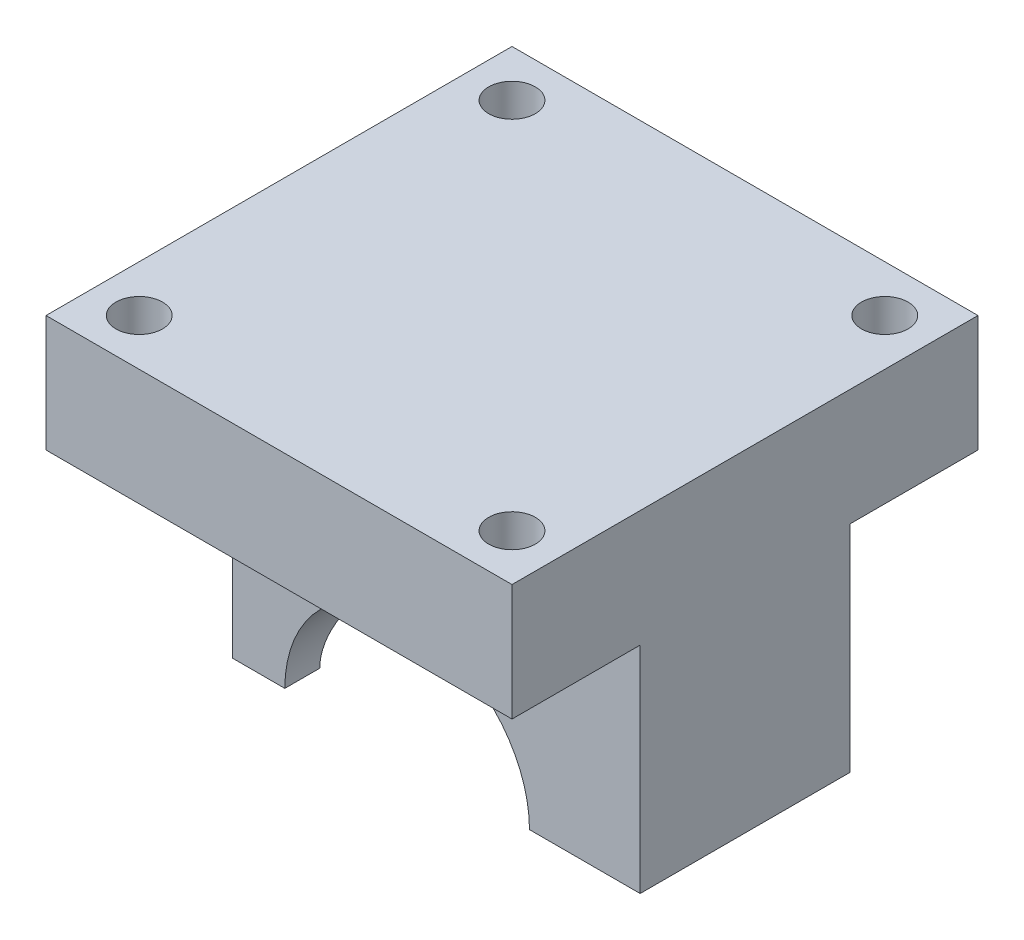
from build123d import *

# Parameters (mm, degrees)
SKETCH1_W           = 40
SKETCH1_H           = 18
BOSS_EXTRUDE1_DEPTH = 18.47
CUT_EXTRUDE1_REACH  = 20
SKETCH2_R           = 10.5
CUT_EXTRUDE3_REACH  = 42
SKETCH4_R           = 6
CUT_EXTRUDE4_REACH  = 20.47
SKETCH5_W           = 5
SKETCH5_H           = 18
SKETCH6_W           = 40
SKETCH6_H           = 40
BOSS_EXTRUDE2_DEPTH = 10
CUT_EXTRUDE5_REACH  = 12
SKETCH7_R           = 2


with BuildPart() as part:
    # Sketch1 → Boss-Extrude1 (new body)
    with BuildSketch(Plane(origin=(0, 0, 0), x_dir=(1, 0, 0), z_dir=(0, 1, 0))):
        Rectangle(SKETCH1_W, SKETCH1_H)
    extrude(amount=BOSS_EXTRUDE1_DEPTH)

    # Sketch2 → Cut-Extrude1 (cut, up to next)
    with BuildSketch(Plane.XY.offset(9), mode=Mode.PRIVATE) as cut_extrude1_sk1:
        Circle(SKETCH2_R)
    cut_extrude1_tool1 = extrude(cut_extrude1_sk1.sketch, amount=-CUT_EXTRUDE1_REACH, mode=Mode.PRIVATE) & part.part
    add(cut_extrude1_tool1.solids().sort_by_distance((0, 0, 9))[0], mode=Mode.SUBTRACT)

    # Sketch4 → Cut-Extrude3 (cut, up to next)
    with BuildSketch(Plane.ZY.offset(20), mode=Mode.PRIVATE) as cut_extrude3_sk1:
        Circle(SKETCH4_R)
    cut_extrude3_tool1 = extrude(cut_extrude3_sk1.sketch, amount=-CUT_EXTRUDE3_REACH, mode=Mode.PRIVATE) & part.part
    add(cut_extrude3_tool1.solids().sort_by_distance((-20, 0, 0))[0], mode=Mode.SUBTRACT)

    # Sketch5 → Cut-Extrude4 (cut, up to next)
    with BuildSketch(Plane.XZ, mode=Mode.PRIVATE) as cut_extrude4_sk1:
        with Locations((-17.5, 0)):
            Rectangle(SKETCH5_W, SKETCH5_H)
    cut_extrude4_tool1 = extrude(cut_extrude4_sk1.sketch, amount=-CUT_EXTRUDE4_REACH, mode=Mode.PRIVATE) & part.part
    add(cut_extrude4_tool1.solids().sort_by_distance((-17.5, 0, 0))[0], mode=Mode.SUBTRACT)

    # Sketch6 → Boss-Extrude2 (add)
    with BuildSketch(Plane(origin=(0, 18.47, 0), x_dir=(1, 0, 0), z_dir=(0, 1, 0))):
        Rectangle(SKETCH6_W, SKETCH6_H)
    extrude(amount=BOSS_EXTRUDE2_DEPTH)

    # Sketch7 → Cut-Extrude5 (cut, up to next)
    with BuildSketch(Plane.XZ.offset(-18.47), mode=Mode.PRIVATE) as cut_extrude5_sk1:
        with Locations((16, 16)):
            Circle(SKETCH7_R)
    cut_extrude5_tool1 = extrude(cut_extrude5_sk1.sketch, amount=-CUT_EXTRUDE5_REACH, mode=Mode.PRIVATE) & part.part
    add(cut_extrude5_tool1.solids().sort_by_distance((16, 18.47, 16))[0], mode=Mode.SUBTRACT)
    # Sketch7 → Cut-Extrude5 (cut, up to next)
    with BuildSketch(Plane.XZ.offset(-18.47), mode=Mode.PRIVATE) as cut_extrude5_sk2:
        with Locations((-16, 16)):
            Circle(SKETCH7_R)
    cut_extrude5_tool2 = extrude(cut_extrude5_sk2.sketch, amount=-CUT_EXTRUDE5_REACH, mode=Mode.PRIVATE) & part.part
    add(cut_extrude5_tool2.solids().sort_by_distance((-16, 18.47, 16))[0], mode=Mode.SUBTRACT)
    # Sketch7 → Cut-Extrude5 (cut, up to next)
    with BuildSketch(Plane.XZ.offset(-18.47), mode=Mode.PRIVATE) as cut_extrude5_sk3:
        with Locations((16, -16)):
            Circle(SKETCH7_R)
    cut_extrude5_tool3 = extrude(cut_extrude5_sk3.sketch, amount=-CUT_EXTRUDE5_REACH, mode=Mode.PRIVATE) & part.part
    add(cut_extrude5_tool3.solids().sort_by_distance((16, 18.47, -16))[0], mode=Mode.SUBTRACT)
    # Sketch7 → Cut-Extrude5 (cut, up to next)
    with BuildSketch(Plane.XZ.offset(-18.47), mode=Mode.PRIVATE) as cut_extrude5_sk4:
        with Locations((-16, -16)):
            Circle(SKETCH7_R)
    cut_extrude5_tool4 = extrude(cut_extrude5_sk4.sketch, amount=-CUT_EXTRUDE5_REACH, mode=Mode.PRIVATE) & part.part
    add(cut_extrude5_tool4.solids().sort_by_distance((-16, 18.47, -16))[0], mode=Mode.SUBTRACT)


solid = part.part
